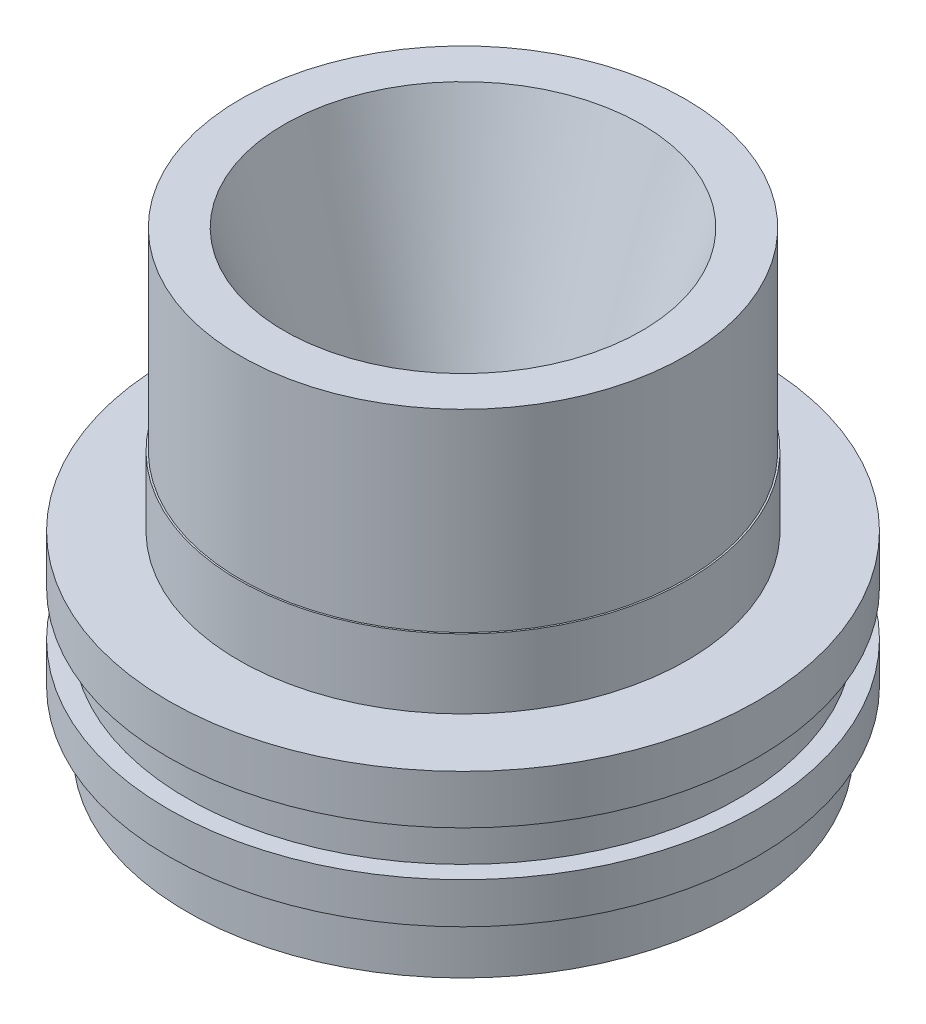
from build123d import *


with BuildPart() as part:
    # Sketch1 → Revolve1 (revolve)
    with BuildSketch(Plane.XY):
        Polygon((-27.833802256, 12.902692784), (-13.589, -31.369507216), (-13.589, -44.069507216), (-40.513, -57.912507216), (-42.926, -57.912507216), (-42.926, -48.946307216), (-45.847, -48.946307216), (-45.847, -42.596307216), (-42.926, -42.596307216), (-42.926, -35.611307216), (-45.847, -35.611307216), (-45.847, -27.991307216), (-34.8996, -27.991307216), (-34.8996, -17.196307216), (-34.6456, -17.196307216), (-34.6456, 12.902692784), align=None)
    revolve(axis=Axis((0, 0, 0), (0, 1, 0)))


solid = part.part
